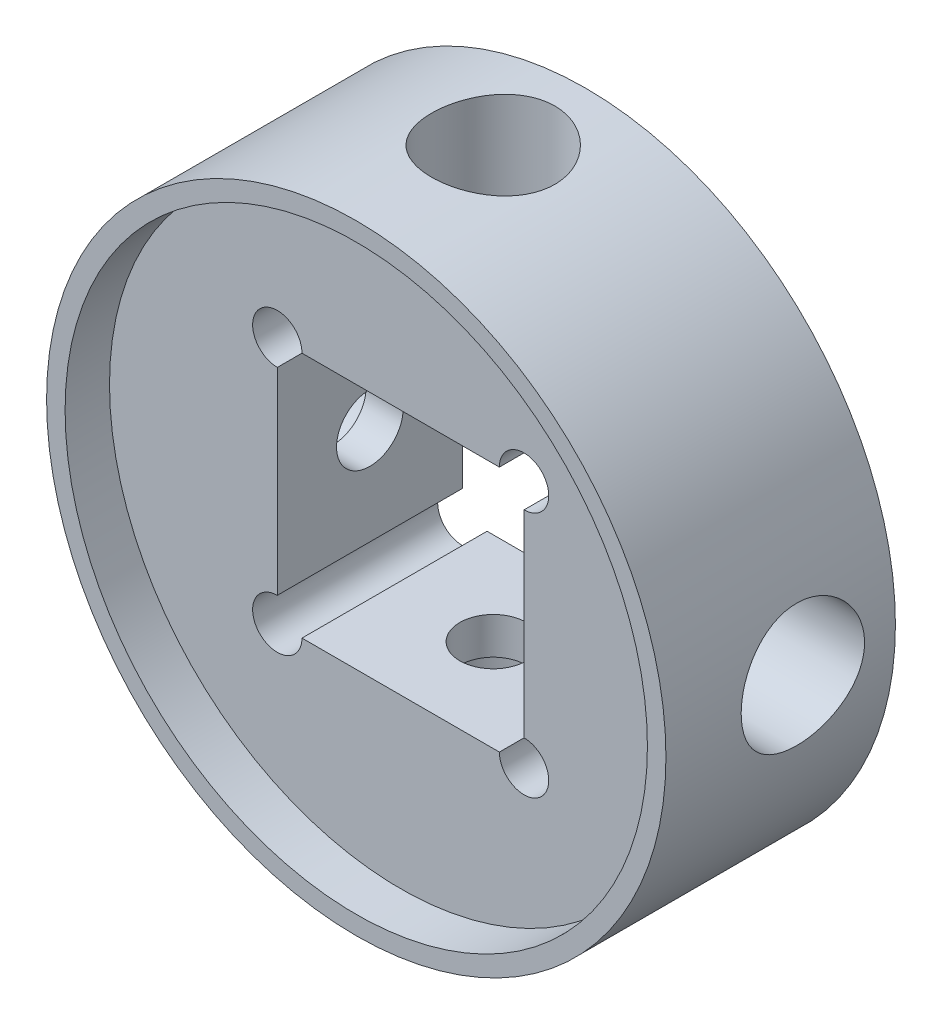
from build123d import *

# Parameters (mm, degrees)
SKIZZE1_R                            = 25.1
SKIZZE1_W                            = 20
SKIZZE1_H                            = 20
AUFSATZ_LINEAR_AUSTRAGEN1_DEPTH      = 15
SKIZZE2_R                            = 25.1
SKIZZE2_R_2                          = 23.6
AUFSATZ_LINEAR_AUSTRAGEN2_DEPTH      = 3.6
SKIZZE3_R                            = 2
SCHNITT_LINEAR_AUSTRAGEN2_DEPTH      = 41.074680286
SCHNITT_LINEAR_AUSTRAGEN3_DEPTH      = 41.074680286
SCHNITT_LINEAR_AUSTRAGEN3_DEPTH_BACK = 41.074680286
SKIZZE4_R                            = 2.7
SCHNITT_LINEAR_AUSTRAGEN4_DEPTH      = 41.074680457
SCHNITT_LINEAR_AUSTRAGEN4_DEPTH_BACK = 41.074680457
SKIZZE5_R                            = 2.7
SCHNITT_LINEAR_START                 = 13
SKIZZE4_3_R                          = 5
SCHNITT_LINEAR_AUSTRAGEN5_DEPTH      = 28.074680457
SKIZZE5_3_R                          = 5
SCHNITT_LINEAR_AUSTRAGEN6_DEPTH      = 28.074680457


with BuildPart() as part:
    # Skizze1 → Aufsatz-Linear austragen1 (new body)
    with BuildSketch(Plane.XY):
        Circle(SKIZZE1_R)
        Rectangle(SKIZZE1_W, SKIZZE1_H, mode=Mode.SUBTRACT)
    extrude(amount=AUFSATZ_LINEAR_AUSTRAGEN1_DEPTH)

    # Skizze2 → Aufsatz-Linear austragen2 (add)
    with BuildSketch(Plane.XY.offset(15)):
        Circle(SKIZZE2_R)
        Circle(SKIZZE2_R_2, mode=Mode.SUBTRACT)
    extrude(amount=AUFSATZ_LINEAR_AUSTRAGEN2_DEPTH)

    # Skizze3 → Schnitt-Linear austragen2 (cut, through all)
    with BuildSketch(Plane.XY):
        with Locations((-10, 10)):
            Circle(SKIZZE3_R)
        with Locations((10, 10)):
            Circle(SKIZZE3_R)
        with Locations((10, -10)):
            Circle(SKIZZE3_R)
        with Locations((-10, -10)):
            Circle(SKIZZE3_R)
    extrude(amount=SCHNITT_LINEAR_AUSTRAGEN2_DEPTH, mode=Mode.SUBTRACT)

    # Skizze4 → Schnitt-Linear austragen3 (cut, two sides: drawn at the far end of the back side and taken through both)
    with BuildSketch(Plane(origin=(0, 0, 0), x_dir=(1, 0, 0), z_dir=(0, 1, 0)).offset(-SCHNITT_LINEAR_AUSTRAGEN3_DEPTH_BACK)):
        with Locations((0, -7.5)):
            Circle(SKIZZE4_R)
    extrude(amount=SCHNITT_LINEAR_AUSTRAGEN3_DEPTH + SCHNITT_LINEAR_AUSTRAGEN3_DEPTH_BACK, mode=Mode.SUBTRACT)

    # Skizze5 → Schnitt-Linear austragen4 (cut, two sides: drawn at the far end of the back side and taken through both)
    with BuildSketch(Plane(origin=(0, 0, 0), x_dir=(0, 0, -1), z_dir=(1, 0, 0)).offset(-SCHNITT_LINEAR_AUSTRAGEN4_DEPTH_BACK)):
        with Locations((-7.5, 0)):
            Circle(SKIZZE5_R)
    extrude(amount=SCHNITT_LINEAR_AUSTRAGEN4_DEPTH + SCHNITT_LINEAR_AUSTRAGEN4_DEPTH_BACK, mode=Mode.SUBTRACT)

    # Skizze4_3 → Schnitt-Linear austragen5 (cut, through all)
    with BuildSketch(Plane(origin=(0, 0, 0), x_dir=(1, 0, 0), z_dir=(0, 1, 0)).offset(SCHNITT_LINEAR_START)):
        with Locations((0, -7.5)):
            Circle(SKIZZE4_3_R)
    schnitt_linear_austragen5 = extrude(amount=SCHNITT_LINEAR_AUSTRAGEN5_DEPTH, mode=Mode.SUBTRACT)

    # Spiegeln1: Schnitt-Linear austragen5 across plane
    add(schnitt_linear_austragen5.mirror(Plane.ZX), mode=Mode.SUBTRACT)

    # Skizze5_3 → Schnitt-Linear austragen6 (cut, through all)
    with BuildSketch(Plane(origin=(0, 0, 0), x_dir=(0, 0, -1), z_dir=(1, 0, 0)).offset(SCHNITT_LINEAR_START)):
        with Locations((-7.5, 0)):
            Circle(SKIZZE5_3_R)
    schnitt_linear_austragen6 = extrude(amount=SCHNITT_LINEAR_AUSTRAGEN6_DEPTH, mode=Mode.SUBTRACT)

    # Spiegeln2: Schnitt-Linear austragen6 across plane
    add(schnitt_linear_austragen6.mirror(Plane(origin=(0, 0, 0), x_dir=(0, 0, 1), z_dir=(1, 0, 0))), mode=Mode.SUBTRACT)


solid = part.part
